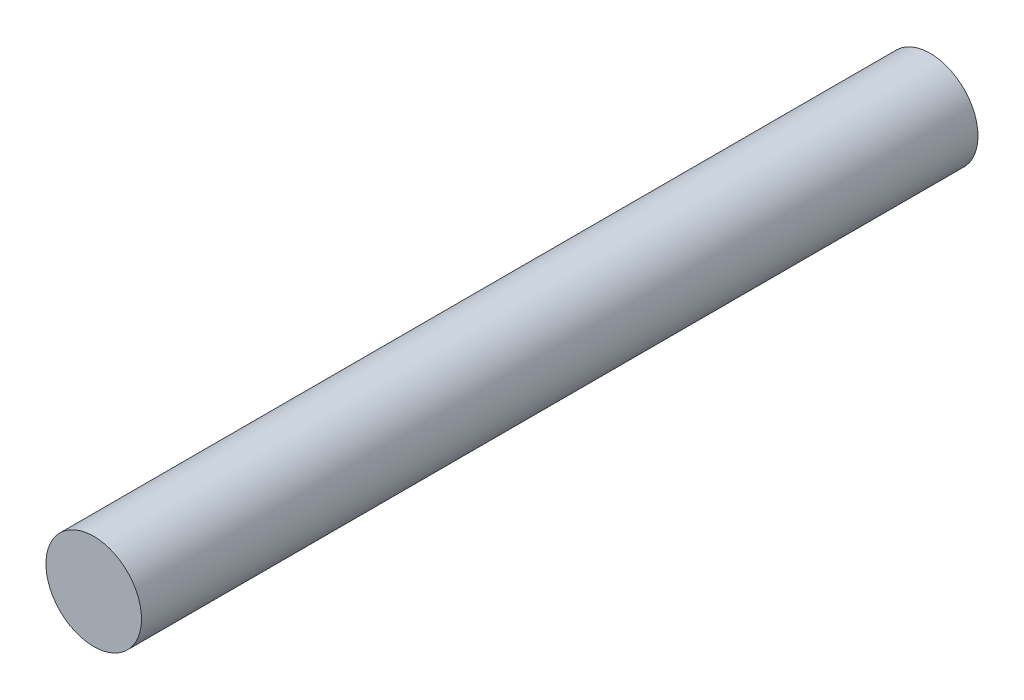
from build123d import *

# Parameters (mm, degrees)
SKETCH1_R           = 4
BOSS_EXTRUDE1_DEPTH = 70


with BuildPart() as part:
    # Sketch1 → Boss-Extrude1 (new body)
    with BuildSketch(Plane.XY):
        Circle(SKETCH1_R)
    extrude(amount=BOSS_EXTRUDE1_DEPTH)


solid = part.part
